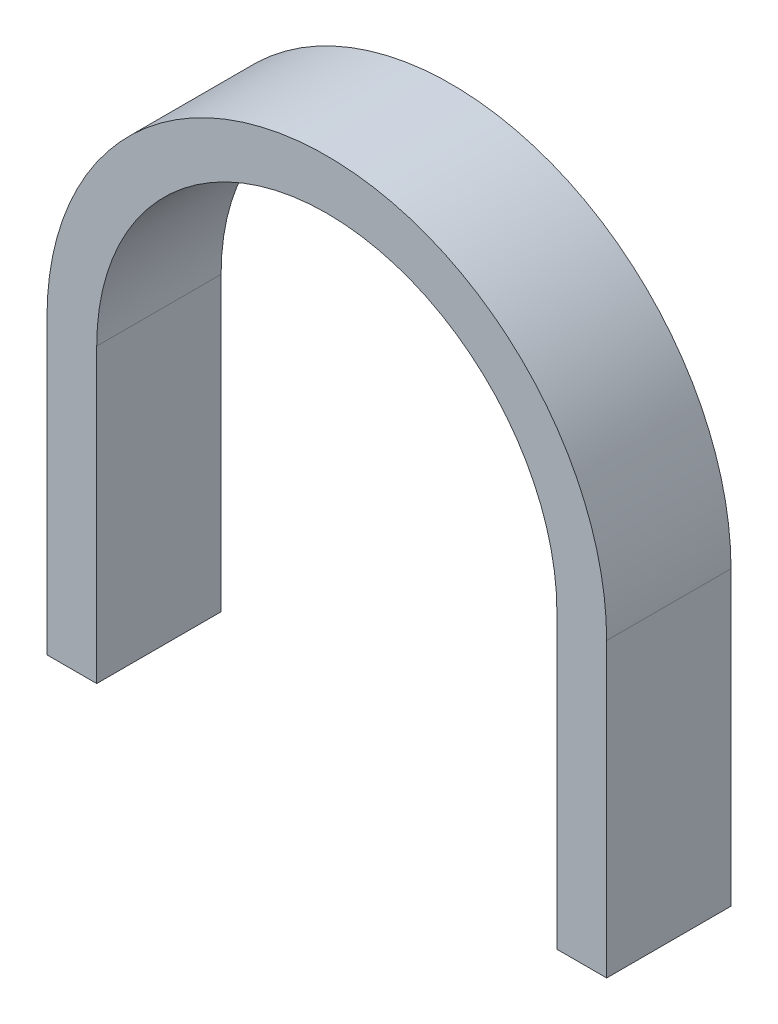
from build123d import *

# Parameters (mm, degrees)
BOSS_EXTRUDE1_DEPTH = 10
SKETCH2_W           = 4
SKETCH2_H           = 10
BOSS_EXTRUDE2_DEPTH = 5


with BuildPart() as part:
    # Sketch1 → Boss-Extrude1 (new body)
    with BuildSketch(Plane.XY):
        with BuildLine():
            Line((18.5, 18.5), (18.5, 0))
            Line((18.5, 0), (22.5, 0))
            Line((22.5, 0), (22.5, 18.5))
            ThreePointArc((22.5, 18.5), (0, 41), (-22.5, 18.5))
            Line((-22.5, 18.5), (-22.5, 0))
            Line((-22.5, 0), (-18.5, 0))
            Line((-18.5, 0), (-18.5, 18.5))
            ThreePointArc((-18.5, 18.5), (0, 37), (18.5, 18.5))
        make_face()
    extrude(amount=BOSS_EXTRUDE1_DEPTH)

    # Sketch2 → Boss-Extrude2 (add)
    with BuildSketch(Plane.XZ):
        with Locations((20.5, 5)):
            Rectangle(SKETCH2_W, SKETCH2_H)
        with Locations((-20.5, 5)):
            Rectangle(SKETCH2_W, SKETCH2_H)
    extrude(amount=BOSS_EXTRUDE2_DEPTH)


solid = part.part
